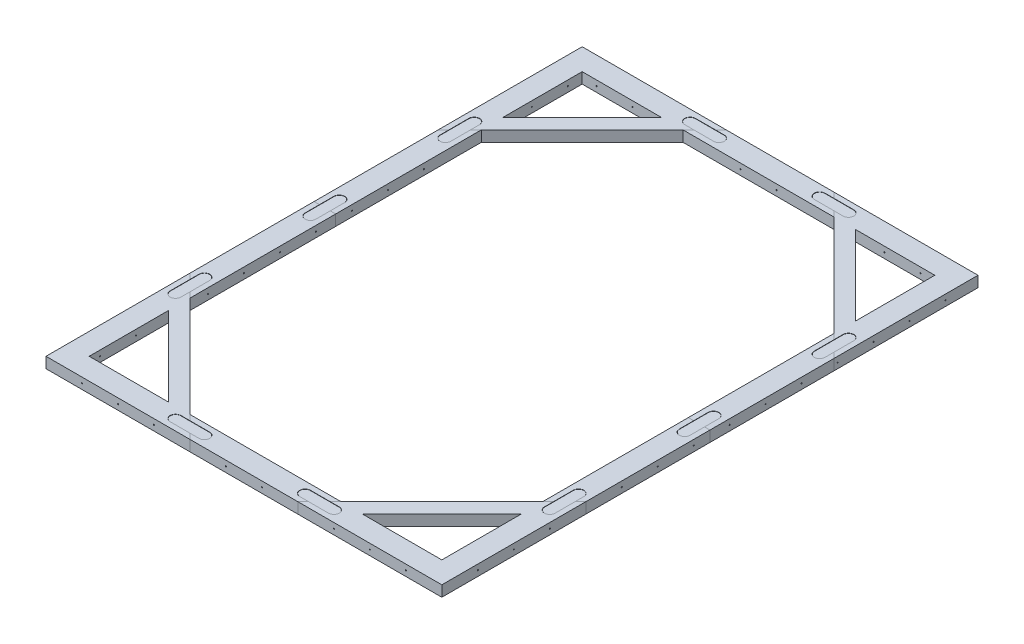
from build123d import *

# Parameters (mm, degrees)
SKETCH1_W               = 550
SKETCH1_H               = 745
BOSS_EXTRUDE1_DEPTH     = 15
CUT_EXTRUDE1_DEPTH      = 15
SKETCH3_W               = 30
SKETCH3_H               = 0.0001
CUT_EXTRUDE_THIN1_DEPTH = 15
CUT_EXTRUDE2_DEPTH      = 5
BOSS_EXTRUDE2_DEPTH     = 4.8
BOSS_EXTRUDE2_2_DEPTH   = 4.8
BOSS_EXTRUDE2_3_DEPTH   = 4.8
BOSS_EXTRUDE2_4_DEPTH   = 4.8
BOSS_EXTRUDE2_5_DEPTH   = 4.8
BOSS_EXTRUDE2_6_DEPTH   = 4.8
BOSS_EXTRUDE2_7_DEPTH   = 4.8
BOSS_EXTRUDE2_8_DEPTH   = 4.8
BOSS_EXTRUDE2_9_DEPTH   = 4.8
BOSS_EXTRUDE2_10_DEPTH  = 4.8
SKETCH8_R               = 0.75
CUT_EXTRUDE3_DEPTH      = 30
SKETCH9_R               = 0.75
CUT_EXTRUDE4_DEPTH      = 30
SKETCH10_R              = 0.75
CUT_EXTRUDE5_DEPTH      = 30
SKETCH11_R              = 0.75
CUT_EXTRUDE6_DEPTH      = 30


with BuildPart() as part:
    # Sketch1 → Boss-Extrude1 (new body)
    with BuildSketch(Plane(origin=(0, 0, 0), x_dir=(1, 0, 0), z_dir=(0, 1, 0))):
        with Locations((275, 372.5)):
            Rectangle(SKETCH1_W, SKETCH1_H)
        Polygon((170, 715), (30, 575), (30, 170), (170, 30), (380, 30), (520, 170), (520, 575), (380, 715), align=None, mode=Mode.SUBTRACT)
    extrude(amount=BOSS_EXTRUDE1_DEPTH)

    # Sketch2 → Cut-Extrude1 (cut)
    with BuildSketch(Plane(origin=(0, 15, 0), x_dir=(1, 0, 0), z_dir=(0, 1, 0))):
        Polygon((140, 715), (30, 715), (30, 605), align=None)
        Polygon((520, 715), (520, 605), (410, 715), align=None)
        Polygon((410, 30), (520, 30), (520, 140), align=None)
        Polygon((30, 30), (30, 140), (140, 30), align=None)
    extrude(amount=-CUT_EXTRUDE1_DEPTH, mode=Mode.SUBTRACT)

    # Sketch3 → Cut-Extrude-Thin1 (cut)
    with BuildSketch(Plane(origin=(0, 15, 0), x_dir=(1, 0, 0), z_dir=(0, 1, 0))):
        Polygon((170.000035355, 714.999964645), (200.000035355, 744.999964645), (199.999964645, 745.000035355), (169.999964645, 715.000035355), align=None)
        Polygon((380.000035355, 715.000035355), (350.000035355, 745.000035355), (349.999964645, 744.999964645), (379.999964645, 714.999964645), align=None)
        Polygon((29.999964645, 575.000035355), (-3.5355e-05, 545.000035355), (3.5355e-05, 544.999964645), (30.000035355, 574.999964645), align=None)
        Polygon((519.999964645, 574.999964645), (549.999964645, 544.999964645), (550.000035355, 545.000035355), (520.000035355, 575.000035355), align=None)
        Polygon((30.000035355, 170.000035355), (3.5355e-05, 200.000035355), (-3.5355e-05, 199.999964645), (29.999964645, 169.999964645), align=None)
        Polygon((169.999964645, 29.999964645), (199.999964645, -3.5355e-05), (200.000035355, 3.5355e-05), (170.000035355, 30.000035355), align=None)
        Polygon((520.000035355, 169.999964645), (550.000035355, 199.999964645), (549.999964645, 200.000035355), (519.999964645, 170.000035355), align=None)
        Polygon((379.999964645, 30.000035355), (349.999964645, 3.5355e-05), (350.000035355, -3.5355e-05), (380.000035355, 29.999964645), align=None)
        with Locations((15, 372.5)):
            Rectangle(SKETCH3_W, SKETCH3_H)
        with Locations((535, 372.5)):
            Rectangle(SKETCH3_W, SKETCH3_H)
    extrude(amount=-CUT_EXTRUDE_THIN1_DEPTH, mode=Mode.SUBTRACT)

    # Sketch4 → Cut-Extrude2 (cut)
    with BuildSketch(Plane(origin=(0, 15, 0), x_dir=(1, 0, 0), z_dir=(0, 1, 0))):
        with BuildLine():
            Line((164.999946967, 737.500017678), (204.999946967, 737.500017678))
            ThreePointArc((204.999946967, 737.500017678), (212.499946967, 730.000017678), (204.999946967, 722.500017678))
            Line((204.999946967, 722.500017678), (164.999946967, 722.500017678))
            ThreePointArc((164.999946967, 722.500017678), (157.499946967, 730.000017678), (164.999946967, 737.500017678))
        make_face()
        with BuildLine():
            Line((385.000053033, 737.500017678), (345.000053033, 737.500017678))
            ThreePointArc((345.000053033, 737.500017678), (337.500053033, 730.000017678), (345.000053033, 722.500017678))
            Line((345.000053033, 722.500017678), (385.000053033, 722.500017678))
            ThreePointArc((385.000053033, 722.500017678), (392.500053033, 730.000017678), (385.000053033, 737.500017678))
        make_face()
        with BuildLine():
            Line((385.000053033, 7.499882322), (345.000053033, 7.499882322))
            ThreePointArc((345.000053033, 7.499882322), (337.500053033, 14.999882322), (345.000053033, 22.499882322))
            Line((345.000053033, 22.499882322), (385.000053033, 22.499882322))
            ThreePointArc((385.000053033, 22.499882322), (392.500053033, 14.999882322), (385.000053033, 7.499882322))
        make_face()
        with BuildLine():
            Line((164.999946967, 7.499882322), (204.999946967, 7.499882322))
            ThreePointArc((204.999946967, 7.499882322), (212.499946967, 14.999882322), (204.999946967, 22.499882322))
            Line((204.999946967, 22.499882322), (164.999946967, 22.499882322))
            ThreePointArc((164.999946967, 22.499882322), (157.499946967, 14.999882322), (164.999946967, 7.499882322))
        make_face()
        with BuildLine():
            Line((22.499982322, 580.000053033), (22.499982322, 540.000053033))
            ThreePointArc((22.499982322, 540.000053033), (14.999982322, 532.500053033), (7.499982322, 540.000053033))
            Line((7.499982322, 540.000053033), (7.499982322, 580.000053033))
            ThreePointArc((7.499982322, 580.000053033), (14.999982322, 587.500053033), (22.499982322, 580.000053033))
        make_face()
        with BuildLine():
            Line((22.499982322, 164.999846967), (22.499982322, 204.999846967))
            ThreePointArc((22.499982322, 204.999846967), (14.999982322, 212.499846967), (7.499982322, 204.999846967))
            Line((7.499982322, 204.999846967), (7.499982322, 164.999846967))
            ThreePointArc((7.499982322, 164.999846967), (14.999982322, 157.499846967), (22.499982322, 164.999846967))
        make_face()
        with BuildLine():
            Line((527.500017678, 580.000053033), (527.500017678, 540.000053033))
            ThreePointArc((527.500017678, 540.000053033), (535.000017678, 532.500053033), (542.500017678, 540.000053033))
            Line((542.500017678, 540.000053033), (542.500017678, 580.000053033))
            ThreePointArc((542.500017678, 580.000053033), (535.000017678, 587.500053033), (527.500017678, 580.000053033))
        make_face()
        with BuildLine():
            Line((527.500017678, 164.999846967), (527.500017678, 204.999846967))
            ThreePointArc((527.500017678, 204.999846967), (535.000017678, 212.499846967), (542.500017678, 204.999846967))
            Line((542.500017678, 204.999846967), (542.500017678, 164.999846967))
            ThreePointArc((542.500017678, 164.999846967), (535.000017678, 157.499846967), (527.500017678, 164.999846967))
        make_face()
        with BuildLine():
            Line((22.499982322, 392.49995), (22.499982322, 352.49995))
            ThreePointArc((22.499982322, 352.49995), (14.999982322, 344.99995), (7.499982322, 352.49995))
            Line((7.499982322, 352.49995), (7.499982322, 392.49995))
            ThreePointArc((7.499982322, 392.49995), (14.999982322, 399.99995), (22.499982322, 392.49995))
        make_face()
        with BuildLine():
            Line((527.500017678, 392.49995), (527.500017678, 352.49995))
            ThreePointArc((527.500017678, 352.49995), (535.000017678, 344.99995), (542.500017678, 352.49995))
            Line((542.500017678, 352.49995), (542.500017678, 392.49995))
            ThreePointArc((542.500017678, 392.49995), (535.000017678, 399.99995), (527.500017678, 392.49995))
        make_face()
    extrude(amount=-CUT_EXTRUDE2_DEPTH, mode=Mode.SUBTRACT)

    # Sketch8 → Cut-Extrude3 (cut)
    with BuildSketch(Plane.XY):
        with Locations((50, 7.5)):
            Circle(SKETCH8_R)
        with Locations((100, 7.5)):
            Circle(SKETCH8_R)
        with Locations((150, 7.5)):
            Circle(SKETCH8_R)
        with Locations((250, 7.5)):
            Circle(SKETCH8_R)
        with Locations((300, 7.5)):
            Circle(SKETCH8_R)
        with Locations((400, 7.5)):
            Circle(SKETCH8_R)
        with Locations((450, 7.5)):
            Circle(SKETCH8_R)
        with Locations((500, 7.5)):
            Circle(SKETCH8_R)
    extrude(amount=-CUT_EXTRUDE3_DEPTH, mode=Mode.SUBTRACT)

    # Sketch9 → Cut-Extrude4 (cut)
    with BuildSketch(Plane(origin=(550, 0, 0), x_dir=(0, 0, -1), z_dir=(1, 0, 0))):
        with Locations((50, 7.5)):
            Circle(SKETCH9_R)
        with Locations((100, 7.5)):
            Circle(SKETCH9_R)
        with Locations((150, 7.5)):
            Circle(SKETCH9_R)
        with Locations((250, 7.5)):
            Circle(SKETCH9_R)
        with Locations((300, 7.5)):
            Circle(SKETCH9_R)
        with Locations((350, 7.5)):
            Circle(SKETCH9_R)
        with Locations((400, 7.5)):
            Circle(SKETCH9_R)
        with Locations((450, 7.5)):
            Circle(SKETCH9_R)
        with Locations((500, 7.5)):
            Circle(SKETCH9_R)
        with Locations((550, 7.5)):
            Circle(SKETCH9_R)
        with Locations((600, 7.5)):
            Circle(SKETCH9_R)
        with Locations((650, 7.5)):
            Circle(SKETCH9_R)
        with Locations((700, 7.5)):
            Circle(SKETCH9_R)
    extrude(amount=-CUT_EXTRUDE4_DEPTH, mode=Mode.SUBTRACT)

    # Sketch10 → Cut-Extrude5 (cut)
    with BuildSketch(Plane(origin=(0, 0, -745), x_dir=(-1, 0, 0), z_dir=(0, 0, -1))):
        with Locations((-500, 7.5)):
            Circle(SKETCH10_R)
        with Locations((-450, 7.5)):
            Circle(SKETCH10_R)
        with Locations((-400, 7.5)):
            Circle(SKETCH10_R)
        with Locations((-300, 7.5)):
            Circle(SKETCH10_R)
        with Locations((-250, 7.5)):
            Circle(SKETCH10_R)
        with Locations((-150, 7.5)):
            Circle(SKETCH10_R)
        with Locations((-100, 7.5)):
            Circle(SKETCH10_R)
        with Locations((-50, 7.5)):
            Circle(SKETCH10_R)
    extrude(amount=-CUT_EXTRUDE5_DEPTH, mode=Mode.SUBTRACT)

    # Sketch11 → Cut-Extrude6 (cut)
    with BuildSketch(Plane.ZY):
        with Locations((-695, 7.5)):
            Circle(SKETCH11_R)
        with Locations((-645, 7.5)):
            Circle(SKETCH11_R)
        with Locations((-595, 7.5)):
            Circle(SKETCH11_R)
        with Locations((-495, 7.5)):
            Circle(SKETCH11_R)
        with Locations((-445, 7.5)):
            Circle(SKETCH11_R)
        with Locations((-395, 7.5)):
            Circle(SKETCH11_R)
        with Locations((-345, 7.5)):
            Circle(SKETCH11_R)
        with Locations((-295, 7.5)):
            Circle(SKETCH11_R)
        with Locations((-245, 7.5)):
            Circle(SKETCH11_R)
        with Locations((-195, 7.5)):
            Circle(SKETCH11_R)
        with Locations((-145, 7.5)):
            Circle(SKETCH11_R)
        with Locations((-95, 7.5)):
            Circle(SKETCH11_R)
        with Locations((-45, 7.5)):
            Circle(SKETCH11_R)
    extrude(amount=-CUT_EXTRUDE6_DEPTH, mode=Mode.SUBTRACT)


with BuildPart() as body_2:
    # Sketch5 → Boss-Extrude2 (new body)
    with BuildSketch(Plane(origin=(0, 10, 0), x_dir=(1, 0, 0), z_dir=(0, 1, 0))):
        with BuildLine():
            Line((164.999946967, 22.299882322), (204.999946967, 22.299882322))
            ThreePointArc((204.999946967, 22.299882322), (212.299946967, 14.999882322), (204.999946967, 7.699882322))
            Line((204.999946967, 7.699882322), (164.999946967, 7.699882322))
            ThreePointArc((164.999946967, 7.699882322), (157.699946967, 14.999882322), (164.999946967, 22.299882322))
        make_face()
    extrude(amount=BOSS_EXTRUDE2_DEPTH)


with BuildPart() as body_3:
    # Sketch5 → Boss-Extrude2 2 (new body)
    with BuildSketch(Plane(origin=(0, 10, 0), x_dir=(1, 0, 0), z_dir=(0, 1, 0))):
        with BuildLine():
            Line((7.699982322, 392.49995), (7.699982322, 352.49995))
            ThreePointArc((7.699982322, 352.49995), (14.999982322, 345.19995), (22.299982322, 352.49995))
            Line((22.299982322, 352.49995), (22.299982322, 392.49995))
            ThreePointArc((22.299982322, 392.49995), (14.999982322, 399.79995), (7.699982322, 392.49995))
        make_face()
    extrude(amount=BOSS_EXTRUDE2_2_DEPTH)


with BuildPart() as body_4:
    # Sketch5 → Boss-Extrude2 3 (new body)
    with BuildSketch(Plane(origin=(0, 10, 0), x_dir=(1, 0, 0), z_dir=(0, 1, 0))):
        with BuildLine():
            Line((22.299982322, 204.999846967), (22.299982322, 164.999846967))
            ThreePointArc((22.299982322, 164.999846967), (14.999982322, 157.699846967), (7.699982322, 164.999846967))
            Line((7.699982322, 164.999846967), (7.699982322, 204.999846967))
            ThreePointArc((7.699982322, 204.999846967), (14.999982322, 212.299846967), (22.299982322, 204.999846967))
        make_face()
    extrude(amount=BOSS_EXTRUDE2_3_DEPTH)


with BuildPart() as body_5:
    # Sketch5 → Boss-Extrude2 4 (new body)
    with BuildSketch(Plane(origin=(0, 10, 0), x_dir=(1, 0, 0), z_dir=(0, 1, 0))):
        with BuildLine():
            Line((542.300017678, 392.49995), (542.300017678, 352.49995))
            ThreePointArc((542.300017678, 352.49995), (535.000017678, 345.19995), (527.700017678, 352.49995))
            Line((527.700017678, 352.49995), (527.700017678, 392.49995))
            ThreePointArc((527.700017678, 392.49995), (535.000017678, 399.79995), (542.300017678, 392.49995))
        make_face()
    extrude(amount=BOSS_EXTRUDE2_4_DEPTH)


with BuildPart() as body_6:
    # Sketch5 → Boss-Extrude2 5 (new body)
    with BuildSketch(Plane(origin=(0, 10, 0), x_dir=(1, 0, 0), z_dir=(0, 1, 0))):
        with BuildLine():
            Line((542.300017678, 204.999846967), (542.300017678, 164.999846967))
            ThreePointArc((542.300017678, 164.999846967), (535.000017678, 157.699846967), (527.700017678, 164.999846967))
            Line((527.700017678, 164.999846967), (527.700017678, 204.999846967))
            ThreePointArc((527.700017678, 204.999846967), (535.000017678, 212.299846967), (542.300017678, 204.999846967))
        make_face()
    extrude(amount=BOSS_EXTRUDE2_5_DEPTH)


with BuildPart() as body_7:
    # Sketch5 → Boss-Extrude2 6 (new body)
    with BuildSketch(Plane(origin=(0, 10, 0), x_dir=(1, 0, 0), z_dir=(0, 1, 0))):
        with BuildLine():
            Line((385.000053033, 22.299882322), (345.000053033, 22.299882322))
            ThreePointArc((345.000053033, 22.299882322), (337.700053033, 14.999882322), (345.000053033, 7.699882322))
            Line((345.000053033, 7.699882322), (385.000053033, 7.699882322))
            ThreePointArc((385.000053033, 7.699882322), (392.300053033, 14.999882322), (385.000053033, 22.299882322))
        make_face()
    extrude(amount=BOSS_EXTRUDE2_6_DEPTH)


with BuildPart() as body_8:
    # Sketch5 → Boss-Extrude2 7 (new body)
    with BuildSketch(Plane(origin=(0, 10, 0), x_dir=(1, 0, 0), z_dir=(0, 1, 0))):
        with BuildLine():
            Line((542.300086045, 540.000043931), (542.300102372, 580.000043931))
            ThreePointArc((542.300102372, 580.000043931), (535.000105351, 587.300046911), (527.700102372, 580.00004989))
            Line((527.700102372, 580.00004989), (527.700086045, 540.00004989))
            ThreePointArc((527.700086045, 540.00004989), (535.000083065, 532.700046911), (542.300086045, 540.000043931))
        make_face()
    extrude(amount=BOSS_EXTRUDE2_7_DEPTH)


with BuildPart() as body_9:
    # Sketch5 → Boss-Extrude2 8 (new body)
    with BuildSketch(Plane(origin=(0, 10, 0), x_dir=(1, 0, 0), z_dir=(0, 1, 0))):
        with BuildLine():
            Line((7.70005069, 540.000262135), (7.700067016, 580.000262135))
            ThreePointArc((7.700067016, 580.000262135), (15.000069996, 587.300259155), (22.300067016, 580.000256176))
            Line((22.300067016, 580.000256176), (22.30005069, 540.000256176))
            ThreePointArc((22.30005069, 540.000256176), (15.00004771, 532.700259155), (7.70005069, 540.000262135))
        make_face()
    extrude(amount=BOSS_EXTRUDE2_8_DEPTH)


with BuildPart() as body_10:
    # Sketch5 → Boss-Extrude2 9 (new body)
    with BuildSketch(Plane(origin=(0, 10, 0), x_dir=(1, 0, 0), z_dir=(0, 1, 0))):
        with BuildLine():
            Line((165.000089906, 722.700162576), (205.000089906, 722.700146249))
            ThreePointArc((205.000089906, 722.700146249), (212.300092885, 730.000143269), (205.000095865, 737.300146249))
            Line((205.000095865, 737.300146249), (165.000095865, 737.300162576))
            ThreePointArc((165.000095865, 737.300162576), (157.700092885, 730.000165555), (165.000089906, 722.700162576))
        make_face()
    extrude(amount=BOSS_EXTRUDE2_9_DEPTH)


with BuildPart() as body_11:
    # Sketch5 → Boss-Extrude2 10 (new body)
    with BuildSketch(Plane(origin=(0, 10, 0), x_dir=(1, 0, 0), z_dir=(0, 1, 0))):
        with BuildLine():
            Line((385.000201931, 737.30007278), (345.000201931, 737.300089106))
            ThreePointArc((345.000201931, 737.300089106), (337.700198951, 730.000092086), (345.000195972, 722.700089106))
            Line((345.000195972, 722.700089106), (385.000195972, 722.70007278))
            ThreePointArc((385.000195972, 722.70007278), (392.300198951, 730.0000698), (385.000201931, 737.30007278))
        make_face()
    extrude(amount=BOSS_EXTRUDE2_10_DEPTH)


solid = Compound([part.part, body_2.part, body_3.part, body_4.part, body_5.part, body_6.part, body_7.part, body_8.part, body_9.part, body_10.part, body_11.part])
